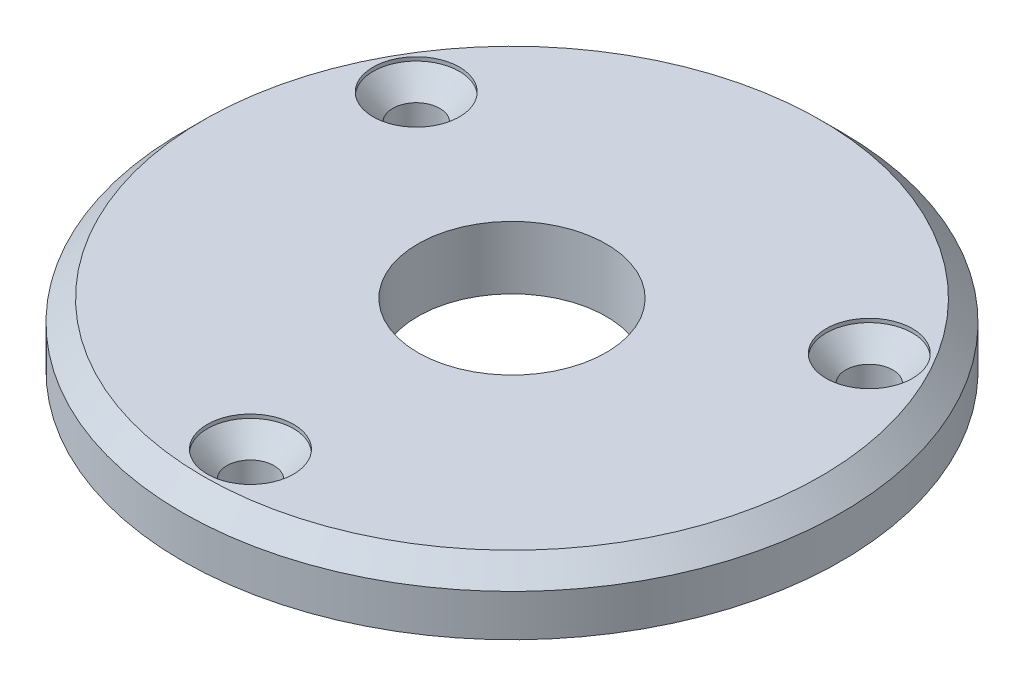
from build123d import *

# Parameters (mm, degrees)
CROQUIS1_R              = 31.5
CROQUIS1_R_2            = 9
SALIENTE_EXTRUIR1_DEPTH = 6
CHAFL_N1_SIZE           = 2
MATRIZC1_COUNT          = 3


with BuildPart() as part:
    # Croquis1 → Saliente-Extruir1 (new body)
    with BuildSketch(Plane(origin=(0, 0, 0), x_dir=(1, 0, 0), z_dir=(0, 1, 0))):
        Circle(CROQUIS1_R)
        Circle(CROQUIS1_R_2, mode=Mode.SUBTRACT)
    extrude(amount=SALIENTE_EXTRUIR1_DEPTH)

    # Chaflán1
    chafl_n1_edges = [part.edges().sort_by_distance(p)[0] for p in [
        (-31.5, 6, 0),
    ]]
    chamfer(chafl_n1_edges, length=CHAFL_N1_SIZE)

    # Croquis2 → Cortar-Revolución1 (revolve, cut)
    with BuildSketch(Plane(origin=(0, 0, 0), x_dir=(0, 0, -1), z_dir=(1, 0, 0))):
        Polygon((-25, 0), (-25, 6), (-20.875, 6), (-20.875, 5.64), (-22.75, 3.52), (-22.75, 0), align=None)
    cortar_revoluci_n1 = revolve(axis=Axis((0, 0, 25), (0, 1, 0)), mode=Mode.SUBTRACT)

    # MatrizC1: Cortar-Revolución1 ×3 about axis
    matrizc1_axis = Axis((0, 0, 0), (0, 1, 0))
    for i in range(1, MATRIZC1_COUNT):
        add(cortar_revoluci_n1.rotate(matrizc1_axis, i * 360 / MATRIZC1_COUNT), mode=Mode.SUBTRACT)


solid = part.part
